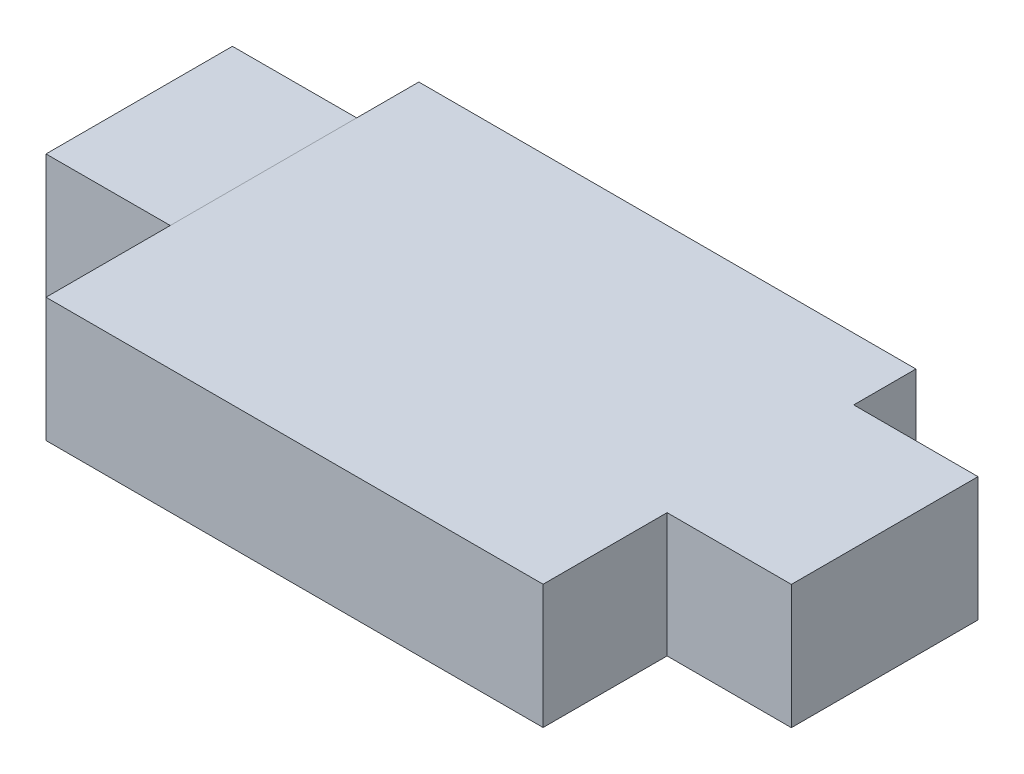
from build123d import *

# Parameters (mm, degrees)
DODANIE_WYCI_GNI_CIE1_DEPTH = 6
SZKIC2_W                    = 3.003669228
SZKIC2_H                    = 1.997379701
DODANIE_WYCI_GNI_CIE2_DEPTH = 2
SZKIC3_W                    = 3.00029081
SZKIC3_H                    = 1.99738112
DODANIE_WYCI_GNI_CIE3_DEPTH = 2


with BuildPart() as part:
    # Szkic1 → Dodanie-wyciągnięcie1 (new body)
    with BuildSketch(Plane.XY):
        Polygon((0, -199.086972688), (0, -197.089592987), (-8, -197.089592987), (-7.997619842, -199.086972688), align=None)
    extrude(amount=-DODANIE_WYCI_GNI_CIE1_DEPTH)

    # Szkic2 → Dodanie-wyciągnięcie2 (add)
    with BuildSketch(Plane(origin=(0, 0, 0), x_dir=(0, 0, -1), z_dir=(1, 0, 0))):
        with Locations((3.49731299, -198.088282838)):
            Rectangle(SZKIC2_W, SZKIC2_H)
    extrude(amount=DODANIE_WYCI_GNI_CIE2_DEPTH)

    # Szkic3 → Dodanie-wyciągnięcie3 (add)
    with BuildSketch(Plane(origin=(-8.234848226, -0.009812978, 0), x_dir=(0, 0, 1), z_dir=(-0.99999929, -0.00119164, 0))):
        with Locations((-3.499897311, -198.078610496)):
            Rectangle(SZKIC3_W, SZKIC3_H)
    extrude(amount=DODANIE_WYCI_GNI_CIE3_DEPTH)


solid = part.part
